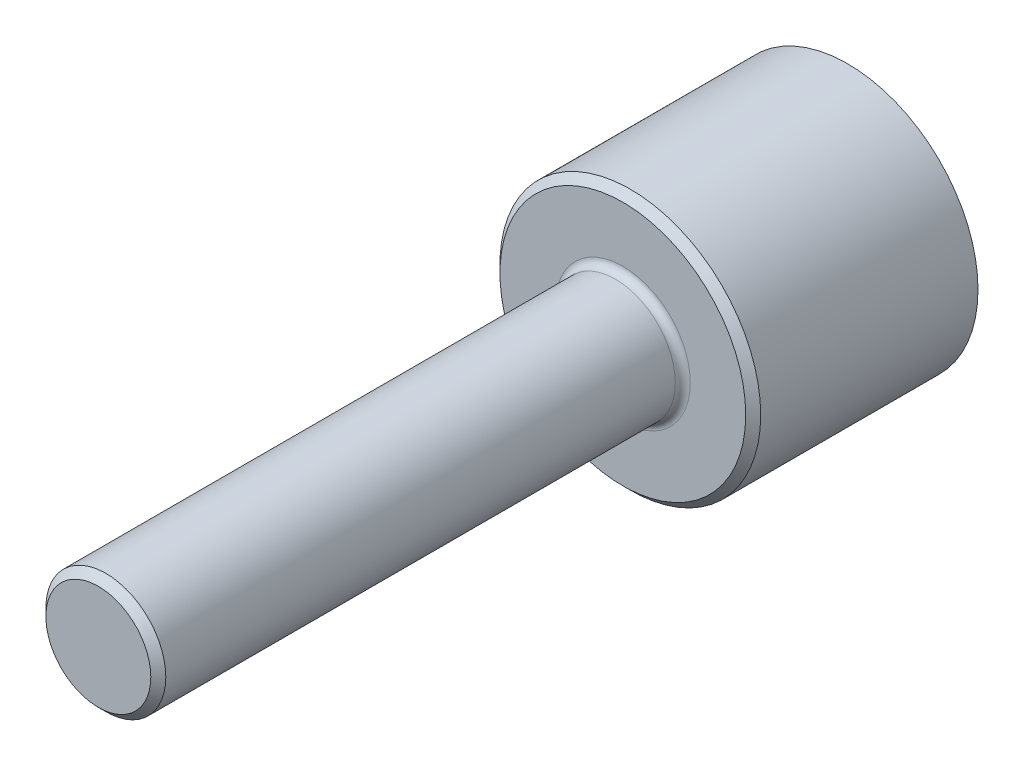
from build123d import *

# Parameters (mm, degrees)
SKETCH1_R     = 17.4
BODY_DEPTH    = 30
SKETCH2_R     = 8
SPIGOT_DEPTH  = 70
CHAMFERS_SIZE = 1
FILLET_2_R    = 1


with BuildPart() as part:
    # Sketch1 → Body (new body)
    with BuildSketch(Plane.XY):
        Circle(SKETCH1_R)
    extrude(amount=BODY_DEPTH)

    # Sketch2 → Spigot (add)
    with BuildSketch(Plane.XY.offset(30)):
        Circle(SKETCH2_R)
    extrude(amount=SPIGOT_DEPTH)

    # Chamfers
    chamfers_edges = [part.edges().sort_by_distance(p)[0] for p in [
        (-17.4, 0, 30),
        (-8, 0, 100),
    ]]
    chamfer(chamfers_edges, length=CHAMFERS_SIZE)

    # Fillet 2
    fillet_2_edges = [part.edges().sort_by_distance(p)[0] for p in [
        (-8, 0, 30),
    ]]
    fillet(fillet_2_edges, radius=FILLET_2_R)


solid = part.part
